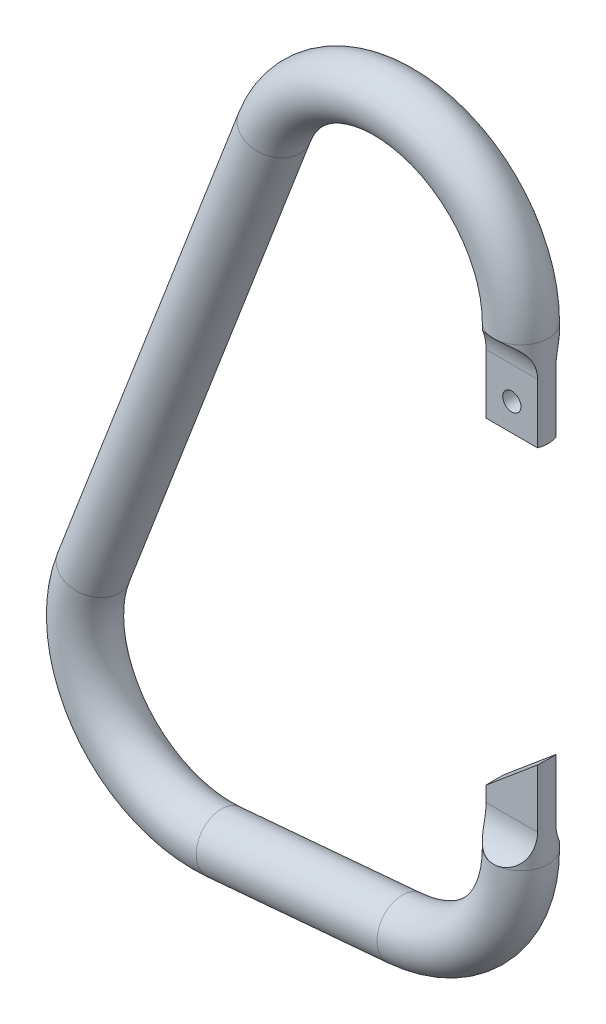
from build123d import *

# Parameters (mm, degrees)
SWEEP1_PROFILE_R        = 1.5
CUT_EXTRUDE1_DEPTH      = 39.877553802
CUT_EXTRUDE1_DEPTH_BACK = 39.877553802
SKETCH7_R               = 0.5
CUT_EXTRUDE10_DEPTH     = 2


with BuildPart() as part:
    # Sweep1: sweep along a path in Sketch2
    with BuildLine(Plane.XY) as sweep1_path:
        Line((0, 0), (0, 5))
        ThreePointArc((0, 5), (-5.724351322, 11.882784353), (-13.535062985, 7.508575647))
        Line((-13.535062985, 7.508575647), (-23.465153554, -18.360194706))
        ThreePointArc((-23.465153554, -18.360194706), (-22.520539139, -25.081475515), (-16.32000037, -27.842133239))
        Line((-16.32000037, -27.842133239), (-6.389909801, -26.973362887))
        ThreePointArc((-6.389909801, -26.973362887), (-1.839058642, -24.729131453), (0, -20))
        Line((0, -20), (0, -15))
    # Sweep1 profile (on start of the path) → Sweep1 (sweep)
    with BuildSketch(Plane.ZX):
        Circle(SWEEP1_PROFILE_R)
    sweep(path=sweep1_path.line)

    # Sketch7 → Cut-Extrude1 (cut, two sides: drawn at the far end of the back side and taken through both)
    with BuildSketch(Plane.XY.offset(-CUT_EXTRUDE1_DEPTH_BACK)):
        with Locations((0, 1.5)):
            Circle(SKETCH7_R)
        Polygon((1.5, -15), (-3.26701437, -19), (-3.26701437, -15), align=None)
    extrude(amount=CUT_EXTRUDE1_DEPTH + CUT_EXTRUDE1_DEPTH_BACK, mode=Mode.SUBTRACT)

    # Sketch9 → Cut-Extrude10 (cut, symmetric)
    with BuildSketch(Plane(origin=(0, 0, 0), x_dir=(0, 0, -1), z_dir=(1, 0, 0))):
        with BuildLine():
            Line((0.5, 0), (0.5, 3.267949192))
            ThreePointArc((0.5, 3.267949192), (0.767949192, 4.267949192), (1.5, 5))
            Line((1.5, 5), (1.5, 0))
            Line((1.5, 0), (0.5, 0))
        make_face()
        with BuildLine():
            Line((0.500000276, -15), (0.500000276, -18.267949352))
            ThreePointArc((0.500000276, -18.267949352), (0.767949389, -19.267949214), (1.5, -20))
            Line((1.5, -20), (1.5, -15))
            Line((1.5, -15), (0.500000276, -15))
        make_face()
    cut_extrude10 = extrude(amount=CUT_EXTRUDE10_DEPTH, both=True, mode=Mode.SUBTRACT)

    # Mirror1: Cut-Extrude10 across plane
    add(cut_extrude10.mirror(Plane.XY), mode=Mode.SUBTRACT)


solid = part.part
